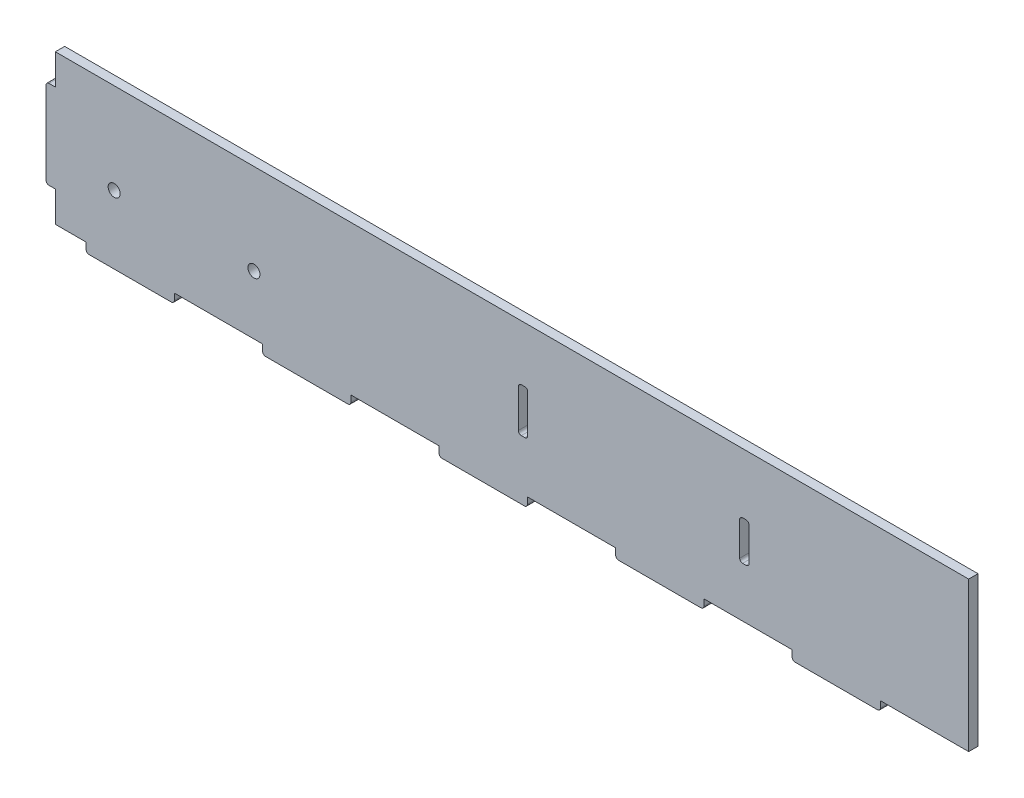
from build123d import *

# Parameters (mm, degrees)
SKETCH1_W           = 310.45
SKETCH1_H           = 50.8
BOSS_EXTRUDE1_DEPTH = 3.175
SKETCH2_R           = 2.05
SKETCH2_R_2         = 2.050488176
SKETCH2_W           = 3.175
SKETCH2_H           = 13.42251169
SKETCH2_H_2         = 15
CUT_EXTRUDE1_DEPTH  = 4.175
SKETCH3_W           = 3.175
SKETCH3_H           = 30
BOSS_EXTRUDE2_DEPTH = 3.175
SKETCH4_W           = 30
SKETCH4_H           = 3.175
BOSS_EXTRUDE3_DEPTH = 3.175
FILLET1_R           = 1


with BuildPart() as part:
    # Sketch1 → Boss-Extrude1 (new body)
    with BuildSketch(Plane.XY):
        Rectangle(SKETCH1_W, SKETCH1_H)
    extrude(amount=BOSS_EXTRUDE1_DEPTH)

    # Sketch2 → Cut-Extrude1 (cut, through all)
    with BuildSketch(Plane.XY.offset(3.175)):
        with Locations((-135.225, -5.4)):
            Circle(SKETCH2_R)
        with Locations((-87.725, -5.4)):
            Circle(SKETCH2_R_2)
        with Locations((78.9675, -1.688744155)):
            Rectangle(SKETCH2_W, SKETCH2_H)
        with Locations((3.7425, -0.9)):
            Rectangle(SKETCH2_W, SKETCH2_H_2)
    extrude(amount=-CUT_EXTRUDE1_DEPTH, mode=Mode.SUBTRACT)

    # Sketch3 → Boss-Extrude2 (add)
    with BuildSketch(Plane.ZY.offset(155.225)):
        with Locations((1.5875, 0)):
            Rectangle(SKETCH3_W, SKETCH3_H)
    extrude(amount=BOSS_EXTRUDE2_DEPTH)

    # Sketch4 → Boss-Extrude3 (add)
    with BuildSketch(Plane.XZ.offset(25.4)):
        with Locations((110.225, 1.5875)):
            Rectangle(SKETCH4_W, SKETCH4_H)
        with Locations((50.225, 1.5875)):
            Rectangle(SKETCH4_W, SKETCH4_H)
        with Locations((-9.775, 1.5875)):
            Rectangle(SKETCH4_W, SKETCH4_H)
        with Locations((-69.775, 1.5875)):
            Rectangle(SKETCH4_W, SKETCH4_H)
        with Locations((-129.775, 1.5875)):
            Rectangle(SKETCH4_W, SKETCH4_H)
    extrude(amount=BOSS_EXTRUDE3_DEPTH)

    # Fillet1
    fillet1_edges = [part.edges().sort_by_distance(p)[0] for p in [
        (-84.775, -28.575, 1.5875),
        (-54.775, -28.575, 1.5875),
        (-144.775, -28.575, 1.5875),
        (-114.775, -28.575, 1.5875),
        (80.555, 5.02251169, 1.5875),
        (80.555, -8.4, 1.5875),
        (77.38, -8.4, 1.5875),
        (77.38, 5.02251169, 1.5875),
        (5.33, 6.6, 1.5875),
        (5.33, -8.4, 1.5875),
        (2.155, -8.4, 1.5875),
        (2.155, 6.6, 1.5875),
        (-158.4, 15, 1.5875),
        (-158.4, -15, 1.5875),
        (125.225, -28.575, 1.5875),
        (95.225, -28.575, 1.5875),
        (35.225, -28.575, 1.5875),
        (65.225, -28.575, 1.5875),
        (-24.775, -28.575, 1.5875),
        (5.225, -28.575, 1.5875),
    ]]
    fillet(fillet1_edges, radius=FILLET1_R)


solid = part.part
